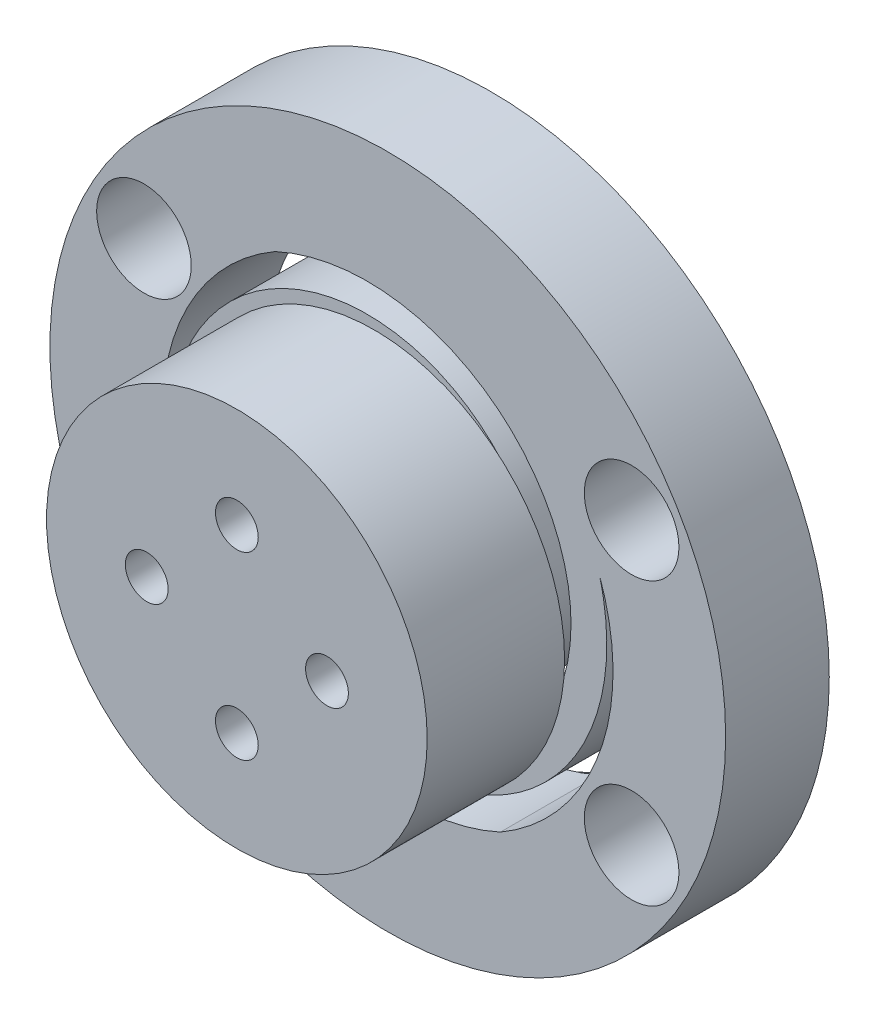
from build123d import *

# Parameters (mm, degrees)
SKETCH_2_R           = 15
SKETCH_2_R_2         = 10
EXTRUDE_2_DEPTH      = 4.6
SKETCH_23_R          = 2.1
CUT_EXTRUDE_8_DEPTH  = 3.1
SKETCH_24_R          = 1.2
CUT_EXTRUDE_9_DEPTH  = 2.5
EXTRUDE_3_DEPTH      = 4.4
SKETCH_19_R          = 4
EXTRUDE_6_DEPTH      = 3.4
SKETCH_9_R           = 3.1
CUT_EXTRUDE_1_DEPTH  = 3.1
SKETCH_10_R          = 4
EXTRUDE_4_DEPTH      = 0.6
SKETCH_11_R          = 8.45
EXTRUDE_5_DEPTH      = 2.5
SKETCH_25_R          = 1
CUT_EXTRUDE_10_DEPTH = 7
CUT_EXTRUDE_11_DEPTH = 1.25
SKETCH_28_R          = 8.45
EXTRUDE_7_DEPTH      = 3.6
EXTRUDE_7_DEPTH_BACK = 2.5
SKETCH_29_R          = 0.95
CUT_EXTRUDE_12_DEPTH = 3


with BuildPart() as part:
    # Sketch 2 → Extrude 2 (new body)
    with BuildSketch(Plane.XY):
        Circle(SKETCH_2_R)
        Circle(SKETCH_2_R_2, mode=Mode.SUBTRACT)
    extrude(amount=EXTRUDE_2_DEPTH)

    # Sketch 23 → Cut-Extrude 8 (cut)
    with BuildSketch(Plane.XY.offset(4.6)):
        with Locations((10.825317547, 6.25)):
            Circle(SKETCH_23_R)
        with Locations((-10.825317547, 6.25)):
            Circle(SKETCH_23_R)
        with Locations((10.825317547, -6.25)):
            Circle(SKETCH_23_R)
        with Locations((-10.825317547, -6.25)):
            Circle(SKETCH_23_R)
    extrude(amount=-CUT_EXTRUDE_8_DEPTH, mode=Mode.SUBTRACT)

    # Sketch 24 → Cut-Extrude 9 (cut, through all)
    with BuildSketch(Plane.XY.offset(1.5)):
        with Locations((-10.825317547, 6.25)):
            Circle(SKETCH_24_R)
        with Locations((10.825317547, 6.25)):
            Circle(SKETCH_24_R)
        with Locations((10.825317547, -6.25)):
            Circle(SKETCH_24_R)
        with Locations((-10.825317547, -6.25)):
            Circle(SKETCH_24_R)
    extrude(amount=-CUT_EXTRUDE_9_DEPTH, mode=Mode.SUBTRACT)

    # Sketch 8 → Extrude 3 (add)
    with BuildSketch(Plane.XY.offset(4.6)):
        with BuildLine():
            ThreePointArc((-2.125, 3.680607966), (-3.993693638, 1.453585609), (-3.993693638, -1.453585609))
            add(Edge.make_bspline(
                [(-9.396926208, -3.420201433), (-9.732062183, -2.149175506), (-9.806172611, -0.835010365), (-9.456725912, 1.676046677), (-9.033681598, 2.871966971), (-7.789656699, 4.972884513), (-6.969506065, 5.877213907), (-5.085556702, 7.278578571), (-4.022753032, 7.775339442), (-1.834341922, 8.316896689), (-0.709724019, 8.361833006), (1.425354593, 8.02880188), (2.434991624, 7.65134079), (4.194832357, 6.566362619), (4.944502403, 5.859612911), (6.091617732, 4.253128009), (6.488888652, 3.354278704), (6.901731194, 1.519508339), (6.917493401, 0.584437672), (6.600877847, -1.174662508), (6.268999982, -1.998016278), (5.34306854, -3.416780201), (4.749719757, -4.011790899), (3.420699316, -4.904656893), (2.685804375, -5.202437862), (1.204674755, -5.486565699), (0.459151326, -5.473153796), (-0.923970423, -5.172953815), (-1.561040931, -4.886659174), (-2.638728045, -4.11977446), (-3.079079395, -3.639826603), (-3.717696054, -2.588270623), (-3.915987072, -2.017330047), (-3.993693638, -1.453585609)],
                knots=[0, 0, 0, 0, 0.0625, 0.0625, 0.125, 0.125, 0.1875, 0.1875, 0.25, 0.25, 0.3125, 0.3125, 0.375, 0.375, 0.4375, 0.4375, 0.5, 0.5, 0.5625, 0.5625, 0.625, 0.625, 0.6875, 0.6875, 0.75, 0.75, 0.8125, 0.8125, 0.875, 0.875, 0.9375, 0.9375, 1, 1, 1, 1], degree=3))
            ThreePointArc((-9.396926208, -3.420201433), (-3.420201433, -9.396926208), (5, -8.660254038))
            add(Edge.make_bspline(
                [(5, -8.660254038), (3.806479564, -9.211009881), (2.525148685, -9.512196786), (-0.008440541, -9.604099447), (-1.259652992, -9.395151506), (-3.544675532, -8.534846644), (-4.577683795, -7.884191092), (-6.284902954, -6.272207574), (-6.958670832, -5.311811899), (-7.872014208, -3.250688101), (-8.111555691, -2.150958779), (-8.154336566, 0.009513438), (-7.957931589, 1.069357245), (-7.195029811, 2.990866525), (-6.629196056, 3.851873198), (-5.246311756, 5.260524443), (-4.430103363, 5.807843469), (-2.694896637, 6.533018535), (-1.776768874, 6.710914596), (0.010586336, 6.704573685), (0.879061498, 6.520711671), (2.437057517, 5.855212978), (3.126062601, 5.37420102), (4.236145931, 4.220415939), (4.657016106, 3.548394826), (5.194022862, 2.139105174), (5.310273501, 1.402578969), (5.254810803, -0.011659233), (5.083491754, -0.688765751), (4.515396145, -1.883248509), (4.119205984, -2.400252004), (3.194520122, -3.21176742), (2.666686289, -3.506188743), (2.125, -3.680607966)],
                knots=[0, 0, 0, 0, 0.0625, 0.0625, 0.125, 0.125, 0.1875, 0.1875, 0.25, 0.25, 0.3125, 0.3125, 0.375, 0.375, 0.4375, 0.4375, 0.5, 0.5, 0.5625, 0.5625, 0.625, 0.625, 0.6875, 0.6875, 0.75, 0.75, 0.8125, 0.8125, 0.875, 0.875, 0.9375, 0.9375, 1, 1, 1, 1], degree=3))
            ThreePointArc((2.125, -3.680607966), (3.993693638, -1.453585609), (3.993693638, 1.453585609))
            add(Edge.make_bspline(
                [(9.396926208, 3.420201433), (9.732062183, 2.149175506), (9.806172611, 0.835010365), (9.456725912, -1.676046677), (9.033681598, -2.871966971), (7.789656699, -4.972884513), (6.969506065, -5.877213907), (5.085556702, -7.278578571), (4.022753032, -7.775339442), (1.834341922, -8.316896689), (0.709724019, -8.361833006), (-1.425354593, -8.02880188), (-2.434991624, -7.65134079), (-4.194832357, -6.566362619), (-4.944502403, -5.859612911), (-6.091617732, -4.253128009), (-6.488888652, -3.354278704), (-6.901731194, -1.519508339), (-6.917493401, -0.584437672), (-6.600877847, 1.174662508), (-6.268999982, 1.998016278), (-5.34306854, 3.416780201), (-4.749719757, 4.011790899), (-3.420699316, 4.904656893), (-2.685804375, 5.202437862), (-1.204674755, 5.486565699), (-0.459151326, 5.473153796), (0.923970423, 5.172953815), (1.561040931, 4.886659174), (2.638728045, 4.11977446), (3.079079395, 3.639826603), (3.717696054, 2.588270623), (3.915987072, 2.017330047), (3.993693638, 1.453585609)],
                knots=[0, 0, 0, 0, 0.0625, 0.0625, 0.125, 0.125, 0.1875, 0.1875, 0.25, 0.25, 0.3125, 0.3125, 0.375, 0.375, 0.4375, 0.4375, 0.5, 0.5, 0.5625, 0.5625, 0.625, 0.625, 0.6875, 0.6875, 0.75, 0.75, 0.8125, 0.8125, 0.875, 0.875, 0.9375, 0.9375, 1, 1, 1, 1], degree=3))
            ThreePointArc((9.396926208, 3.420201433), (3.420201433, 9.396926208), (-5, 8.660254038))
            add(Edge.make_bspline(
                [(-5, 8.660254038), (-3.806479564, 9.211009881), (-2.525148685, 9.512196786), (0.008440541, 9.604099447), (1.259652992, 9.395151506), (3.544675532, 8.534846644), (4.577683795, 7.884191092), (6.284902954, 6.272207574), (6.958670832, 5.311811899), (7.872014208, 3.250688101), (8.111555691, 2.150958779), (8.154336566, -0.009513438), (7.957931589, -1.069357245), (7.195029811, -2.990866525), (6.629196056, -3.851873198), (5.246311756, -5.260524443), (4.430103363, -5.807843469), (2.694896637, -6.533018535), (1.776768874, -6.710914596), (-0.010586336, -6.704573685), (-0.879061498, -6.520711671), (-2.437057517, -5.855212978), (-3.126062601, -5.37420102), (-4.236145931, -4.220415939), (-4.657016106, -3.548394826), (-5.194022862, -2.139105174), (-5.310273501, -1.402578969), (-5.254810803, 0.011659233), (-5.083491754, 0.688765751), (-4.515396145, 1.883248509), (-4.119205984, 2.400252004), (-3.194520122, 3.21176742), (-2.666686289, 3.506188743), (-2.125, 3.680607966)],
                knots=[0, 0, 0, 0, 0.0625, 0.0625, 0.125, 0.125, 0.1875, 0.1875, 0.25, 0.25, 0.3125, 0.3125, 0.375, 0.375, 0.4375, 0.4375, 0.5, 0.5, 0.5625, 0.5625, 0.625, 0.625, 0.6875, 0.6875, 0.75, 0.75, 0.8125, 0.8125, 0.875, 0.875, 0.9375, 0.9375, 1, 1, 1, 1], degree=3))
        make_face()
    extrude(amount=-EXTRUDE_3_DEPTH)

    # Sketch 19 → Extrude 6 (add)
    with BuildSketch(Plane(origin=(0, 0, 0.2), x_dir=(-1, 0, 0), z_dir=(0, 0, -1))):
        Circle(SKETCH_19_R)
    extrude(amount=EXTRUDE_6_DEPTH)

    # Sketch 9 → Cut-Extrude 1 (cut)
    with BuildSketch(Plane(origin=(0, 0, -3.2), x_dir=(-1, 0, 0), z_dir=(0, 0, -1))):
        Circle(SKETCH_9_R)
    extrude(amount=-CUT_EXTRUDE_1_DEPTH, mode=Mode.SUBTRACT)

    # Sketch 10 → Extrude 4 (add)
    with BuildSketch(Plane.XY.offset(4.6)):
        Circle(SKETCH_10_R)
    extrude(amount=EXTRUDE_4_DEPTH)

    # Sketch 11 → Extrude 5 (add)
    with BuildSketch(Plane.XY.offset(5.2)):
        Circle(SKETCH_11_R)
    extrude(amount=EXTRUDE_5_DEPTH)

    # Sketch 12 → Cut-Revolve 1 (revolve, cut)
    with BuildSketch(Plane(origin=(0, 0, 0), x_dir=(0, 0, -1), z_dir=(1, 0, 0))):
        Polygon((-7.7, 8.45), (-5.2, 8.45), (-6.45, 7.15), align=None)
    revolve(axis=Axis((0, 0, 0), (0, 0, 1)), mode=Mode.SUBTRACT)

    # Sketch 25 → Cut-Extrude 10 (cut)
    with BuildSketch(Plane.XY.offset(7.7)):
        Circle(SKETCH_25_R)
    extrude(amount=-CUT_EXTRUDE_10_DEPTH, mode=Mode.SUBTRACT)

    # Sketch 26 → Cut-Extrude 11 (cut)
    with BuildSketch(Plane.XY.offset(7.7)):
        with BuildLine():
            Line((-0.2, 4.095119046), (-0.2, 9))
            Line((-0.2, 9), (0.2, 9))
            Line((0.2, 9), (0.2, 4.095119046))
            ThreePointArc((0.2, 4.095119046), (4.1, 0), (0.2, -4.095119046))
            Line((0.2, -4.095119046), (0.2, -9))
            Line((0.2, -9), (-0.2, -9))
            Line((-0.2, -9), (-0.2, -4.095119046))
            ThreePointArc((-0.2, -4.095119046), (-4.1, 0), (-0.2, 4.095119046))
        make_face()
    extrude(amount=-CUT_EXTRUDE_11_DEPTH, mode=Mode.SUBTRACT)

    # Sketch 28 → Extrude 7 (add, two sides)
    with BuildSketch(Plane.XY.offset(7.7)) as extrude_7_sk:
        Circle(SKETCH_28_R)
    extrude(amount=EXTRUDE_7_DEPTH)
    extrude(extrude_7_sk.sketch, amount=-EXTRUDE_7_DEPTH_BACK)

    # Sketch 29 → Cut-Extrude 12 (cut)
    with BuildSketch(Plane.XY.offset(11.3)):
        with Locations((0, 4)):
            Circle(SKETCH_29_R)
        with Locations((4, 0)):
            Circle(SKETCH_29_R)
        with Locations((0, -4)):
            Circle(SKETCH_29_R)
        with Locations((-4, 0)):
            Circle(SKETCH_29_R)
    extrude(amount=-CUT_EXTRUDE_12_DEPTH, mode=Mode.SUBTRACT)


solid = part.part
